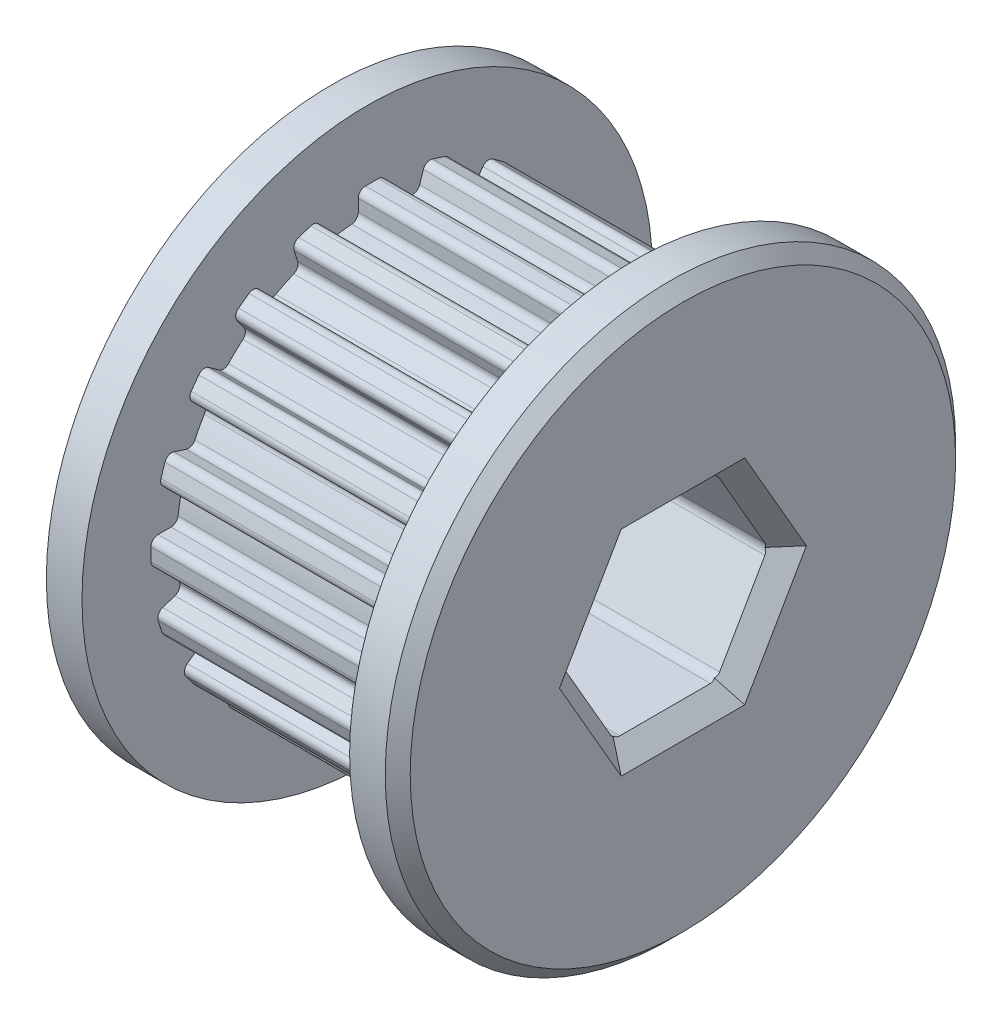
from build123d import *

# Parameters (mm, degrees)
SKETCH2_W                = 0.76
SKETCH2_H                = 0.76
BOSS_EXTRUDE1_DEPTH      = 7
FILLET1_R                = 0.2
CIRPATTERN2_COUNT        = 20
FILLET1_OF_CIRPATTERN2_R = 0.2
CUT_EXTRUDE3_DEPTH       = 10.856423974
CHAMFER1_SIZE            = 0.5
FILLET2_R                = 0.3


with BuildPart() as part:
    # Sketch1 → Revolve2 (revolve)
    with BuildSketch(Plane.XY):
        Polygon((-7.427634387, 2.85), (-7.427634387, 0), (2.428789587, 0), (2.428789587, 5.15), (2.078789587, 5.5), (1.078789587, 5.5), (0.572365613, 3.61), (0.572365613, 2.85), (-6.427634387, 2.85), (-6.427634387, 3.61), (-6.427634387, 5.5), (-7.427634387, 5.5), (-7.427634387, 3.61), align=None)
    revolve(axis=Axis((-7.427634387, -2.5, 0), (1, 0, 0)))

    # Sketch2 → Boss-Extrude1 (add)
    with BuildSketch(Plane.ZY.offset(-0.572365613)):
        with Locations((-0.13, 3.186628075)):
            Rectangle(SKETCH2_W, SKETCH2_H)
    boss_extrude1 = extrude(amount=BOSS_EXTRUDE1_DEPTH)

    # Fillet1
    fillet1_edges = [part.edges().sort_by_distance(p)[0] for p in [
        (-2.927634387, 2.825636112, -0.51),
        (-2.927634387, 3.566628075, -0.51),
        (-2.927634387, 2.844155686, 0.25),
        (-2.927634387, 3.566628075, 0.25),
    ]]
    fillet(fillet1_edges, radius=FILLET1_R)

    # CirPattern2: Boss-Extrude1 ×20 about axis
    cirpattern2_axis = Axis((0, -2.5, 0), (1, 0, 0))
    for i in range(1, CIRPATTERN2_COUNT):
        add(boss_extrude1.rotate(cirpattern2_axis, i * 360 / CIRPATTERN2_COUNT))

    # Fillet1 of CirPattern2
    fillet1_of_cirpattern2_edges = [part.edges().sort_by_distance(p)[0] for p in [
        (-2.927634387, 2.722579595, 1.160673241),
        (-2.927634387, 3.42730483, 1.38965235),
        (-2.927634387, 2.505339841, 1.889199057),
        (-2.927634387, 3.192451914, 2.112455303),
        (-2.927634387, 2.108300599, 2.717731699),
        (-2.927634387, 2.70777569, 3.153275847),
        (-2.927634387, 1.676566458, 3.343470147),
        (-2.927634387, 2.261058898, 3.768128762),
        (-2.927634387, 1.042929033, 4.008759642),
        (-2.927634387, 1.478473181, 4.608234733),
        (-2.927634387, 0.43896165, 4.470459084),
        (-2.927634387, 0.863620265, 5.054951524),
        (-2.927634387, -0.369249112, 4.907382261),
        (-2.927634387, -0.140270003, 5.612107496),
        (-2.927634387, -1.086329201, 5.159848338),
        (-2.927634387, -0.863072955, 5.846960411),
        (-2.927634387, -1.99, 5.325636112),
        (-2.927634387, -1.99, 6.066628075),
        (-2.927634387, -2.75, 5.344155686),
        (-2.927634387, -2.75, 6.066628075),
        (-2.927634387, -3.660673241, 5.222579595),
        (-2.927634387, -3.88965235, 5.92730483),
        (-2.927634387, -4.389199057, 5.005339841),
        (-2.927634387, -4.612455303, 5.692451914),
        (-2.927634387, -5.217731699, 4.608300599),
        (-2.927634387, -5.653275847, 5.20777569),
        (-2.927634387, -5.843470147, 4.176566458),
        (-2.927634387, -6.268128762, 4.761058898),
        (-2.927634387, -6.508759642, 3.542929033),
        (-2.927634387, -7.108234733, 3.978473181),
        (-2.927634387, -6.970459084, 2.93896165),
        (-2.927634387, -7.554951524, 3.363620265),
        (-2.927634387, -7.407382261, 2.130750888),
        (-2.927634387, -8.112107496, 2.359729997),
        (-2.927634387, -7.659848338, 1.413670799),
        (-2.927634387, -8.346960411, 1.636927045),
        (-2.927634387, -7.825636112, 0.51),
        (-2.927634387, -8.566628075, 0.51),
        (-2.927634387, -7.844155686, -0.25),
        (-2.927634387, -8.566628075, -0.25),
        (-2.927634387, -7.722579595, -1.160673241),
        (-2.927634387, -8.42730483, -1.38965235),
        (-2.927634387, -7.505339841, -1.889199057),
        (-2.927634387, -8.192451914, -2.112455303),
        (-2.927634387, -7.108300599, -2.717731699),
        (-2.927634387, -7.70777569, -3.153275847),
        (-2.927634387, -6.676566458, -3.343470147),
        (-2.927634387, -7.261058898, -3.768128762),
        (-2.927634387, -6.042929033, -4.008759642),
        (-2.927634387, -6.478473181, -4.608234733),
        (-2.927634387, -5.43896165, -4.470459084),
        (-2.927634387, -5.863620265, -5.054951524),
        (-2.927634387, -4.630750888, -4.907382261),
        (-2.927634387, -4.859729997, -5.612107496),
        (-2.927634387, -3.913670799, -5.159848338),
        (-2.927634387, -4.136927045, -5.846960411),
        (-2.927634387, -3.01, -5.325636112),
        (-2.927634387, -3.01, -6.066628075),
        (-2.927634387, -2.25, -5.344155686),
        (-2.927634387, -2.25, -6.066628075),
        (-2.927634387, -1.339326759, -5.222579595),
        (-2.927634387, -1.11034765, -5.92730483),
        (-2.927634387, -0.610800943, -5.005339841),
        (-2.927634387, -0.387544697, -5.692451914),
        (-2.927634387, 0.217731699, -4.608300599),
        (-2.927634387, 0.653275847, -5.20777569),
        (-2.927634387, 0.843470147, -4.176566458),
        (-2.927634387, 1.268128762, -4.761058898),
        (-2.927634387, 1.508759642, -3.542929033),
        (-2.927634387, 2.108234733, -3.978473181),
        (-2.927634387, 1.970459084, -2.93896165),
        (-2.927634387, 2.554951524, -3.363620265),
        (-2.927634387, 2.407382261, -2.130750888),
        (-2.927634387, 3.112107496, -2.359729997),
        (-2.927634387, 2.659848338, -1.413670799),
        (-2.927634387, 3.346960411, -1.636927045),
    ]]
    fillet(fillet1_of_cirpattern2_edges, radius=FILLET1_OF_CIRPATTERN2_R)

    # Sketch4 → Cut-Extrude3 (cut, through all)
    with BuildSketch(Plane(origin=(2.428789587, 0, 0), x_dir=(0, 0, -1), z_dir=(1, 0, 0))):
        Polygon((2.886751346, -2.5), (1.443375673, 0), (-1.443375673, 0), (-2.886751346, -2.5), (-1.443375673, -5), (1.443375673, -5), align=None)
    extrude(amount=-CUT_EXTRUDE3_DEPTH, mode=Mode.SUBTRACT)

    # Chamfer1
    chamfer1_edges = [part.edges().sort_by_distance(p)[0] for p in [
        (2.428789587, -1.25, -2.165063509),
        (2.428789587, 0, 0),
        (2.428789587, -1.25, 2.165063509),
        (2.428789587, -3.75, 2.165063509),
        (2.428789587, -5, 0),
        (2.428789587, -3.75, -2.165063509),
        (-7.427634387, -3.75, -2.165063509),
        (-7.427634387, -5, 0),
        (-7.427634387, -3.75, 2.165063509),
        (-7.427634387, -1.25, 2.165063509),
        (-7.427634387, 0, 0),
        (-7.427634387, -1.25, -2.165063509),
    ]]
    chamfer(chamfer1_edges, length=CHAMFER1_SIZE)

    # Fillet2
    fillet2_edges = [part.edges().sort_by_distance(p)[0] for p in [
        (-2.4994224, -2.5, -2.886751346),
        (-2.4994224, 0, -1.443375673),
        (-2.4994224, -5, -1.443375673),
        (-2.4994224, -5, 1.443375673),
        (-2.4994224, -2.5, 2.886751346),
        (-2.4994224, 0, 1.443375673),
    ]]
    fillet(fillet2_edges, radius=FILLET2_R)


solid = part.part
